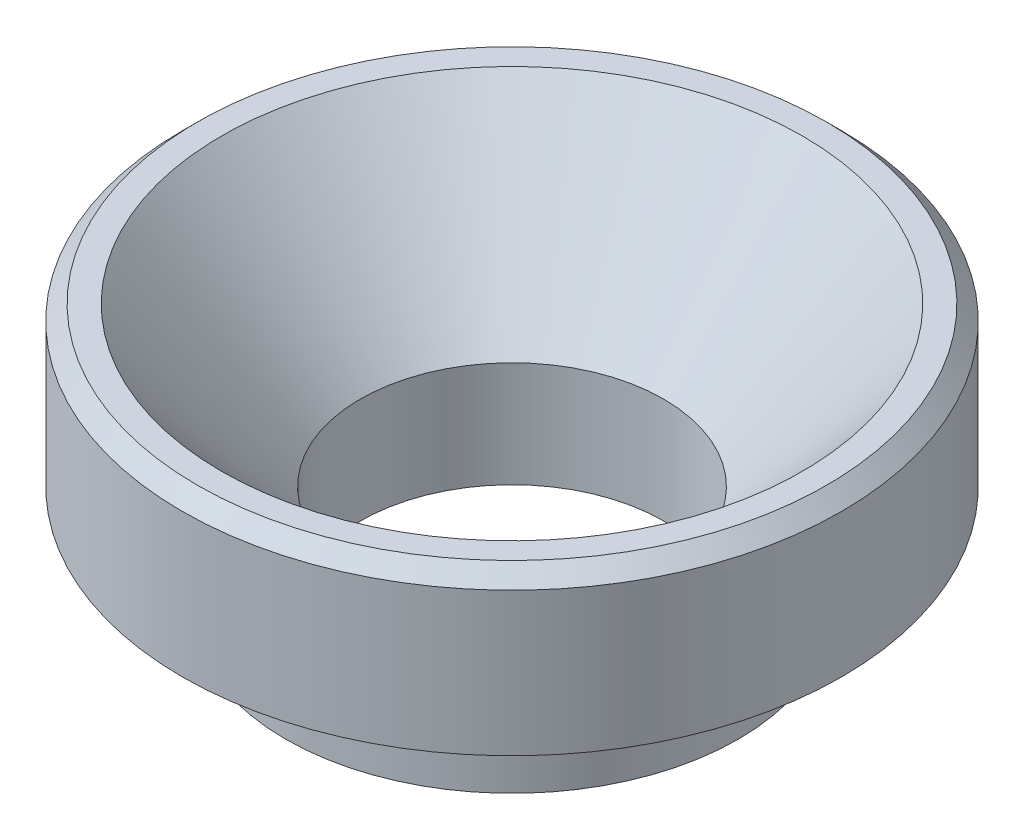
from build123d import *

# Parameters (mm, degrees)
CHAMFER1_SIZE = 0.254
FILLET1_R     = 0.127


with BuildPart() as part:
    # Sketch1 → Revolve1 (revolve)
    with BuildSketch(Plane.XY):
        Polygon((2.5527, 0), (2.5527, 1.778), (4.8895, 4.445), (5.5499, 4.445), (5.5499, 1.778), (3.81, 1.778), (3.81, 0), align=None)
    revolve(axis=Axis((0, 0, 0), (0, 1, 0)))

    # Chamfer1
    chamfer1_edges = [part.edges().sort_by_distance(p)[0] for p in [
        (-5.5499, 4.445, 0),
    ]]
    chamfer(chamfer1_edges, length=CHAMFER1_SIZE)

    # Fillet1
    fillet1_edges = [part.edges().sort_by_distance(p)[0] for p in [
        (-3.81, 1.778, 0),
    ]]
    fillet(fillet1_edges, radius=FILLET1_R)


solid = part.part
